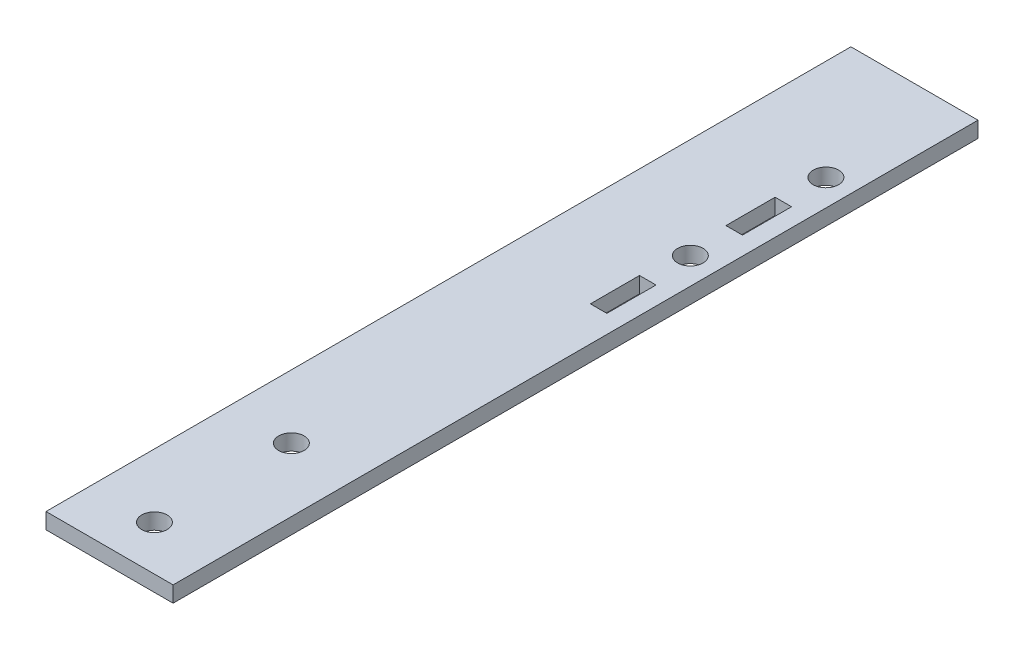
from build123d import *

# Parameters (mm, degrees)
SKETCH1_W           = 19.05
SKETCH1_H           = 2.38125
BOSS_EXTRUDE1_DEPTH = 88.9
SKETCH5_R           = 1.905
CUT_EXTRUDE4_DEPTH  = 3.38125
SKETCH9_W           = 19.05
SKETCH9_H           = 29.6545
BOSS_EXTRUDE4_DEPTH = 2.38125
BOSS_EXTRUDE5_DEPTH = 2.38125
SKETCH11_R          = 1.905
CUT_EXTRUDE6_DEPTH  = 2.54
SKETCH12_W          = 19.05
SKETCH12_H          = 29.6545
CUT_EXTRUDE7_DEPTH  = 3.38125


with BuildPart() as part:
    # Sketch1 → Boss-Extrude1 (new body)
    with BuildSketch(Plane.XY):
        with Locations((9.525, 1.190625)):
            Rectangle(SKETCH1_W, SKETCH1_H)
    extrude(amount=BOSS_EXTRUDE1_DEPTH)

    # Sketch5 → Cut-Extrude4 (cut, through all)
    with BuildSketch(Plane(origin=(0, 2.38125, 0), x_dir=(1, 0, 0), z_dir=(0, 1, 0))):
        with Locations((15.08125, -39.14775)):
            Circle(SKETCH5_R)
        with Locations((15.08125, -18.82775)):
            Circle(SKETCH5_R)
        Polygon((16.317595, -28.98775), (16.317595, -32.5755), (15.08125, -32.5755), (13.844905, -32.5755), (13.844905, -25.2095), (16.317595, -25.2095), align=None)
        Polygon((15.08125, -52.8955), (16.317595, -52.8955), (16.317595, -45.5295), (13.844905, -45.5295), (13.844905, -52.8955), align=None)
    extrude(amount=-CUT_EXTRUDE4_DEPTH, mode=Mode.SUBTRACT)

    # Sketch9 → Boss-Extrude4 (add)
    with BuildSketch(Plane(origin=(0, 2.38125, 0), x_dir=(1, 0, 0), z_dir=(0, 1, 0))):
        with Locations((9.525, 14.82725)):
            Rectangle(SKETCH9_W, SKETCH9_H)
    extrude(amount=-BOSS_EXTRUDE4_DEPTH)

    # Sketch8 → Boss-Extrude5 (add)
    with BuildSketch(Plane(origin=(0, 2.38125, 0), x_dir=(1, 0, 0), z_dir=(0, 1, 0))):
        Polygon((19.05, -88.9), (0, -88.9), (0, -114.3), (0, -120.65), (19.05, -120.65), (19.05, -114.3), align=None)
    extrude(amount=-BOSS_EXTRUDE5_DEPTH)

    # Sketch11 → Cut-Extrude6 (cut)
    with BuildSketch(Plane(origin=(0, 2.38125, 0), x_dir=(1, 0, 0), z_dir=(0, 1, 0))):
        with Locations((9.525, -113.919)):
            Circle(SKETCH11_R)
        with Locations((9.525, -93.3958)):
            Circle(SKETCH11_R)
    extrude(amount=-CUT_EXTRUDE6_DEPTH, mode=Mode.SUBTRACT)

    # Sketch12 → Cut-Extrude7 (cut, through all)
    with BuildSketch(Plane(origin=(0, 2.38125, 0), x_dir=(1, 0, 0), z_dir=(0, 1, 0))):
        with Locations((9.525, 14.82725)):
            Rectangle(SKETCH12_W, SKETCH12_H)
    extrude(amount=-CUT_EXTRUDE7_DEPTH, mode=Mode.SUBTRACT)


solid = part.part
